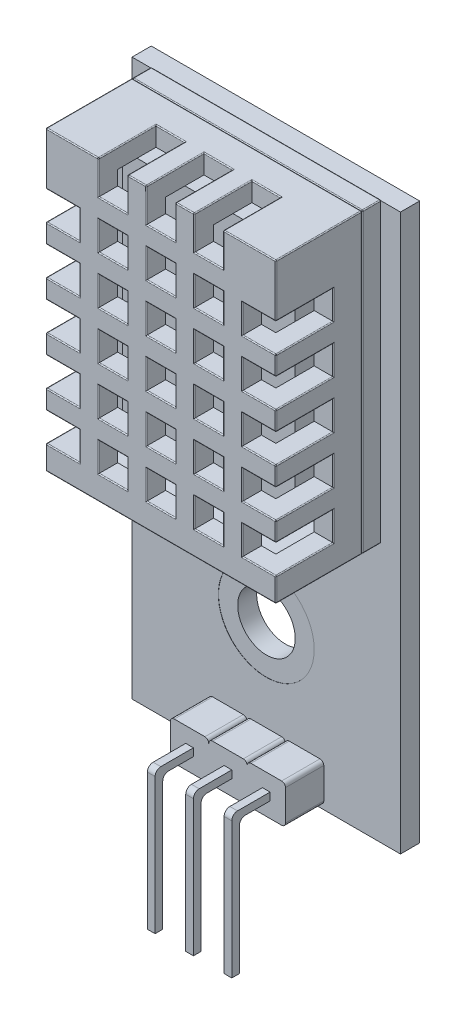
from build123d import *

# Parameters (mm, degrees)
SKETCH1_W           = 12
SKETCH1_H           = 15.5
BOSS_EXTRUDE1_DEPTH = 5.5
SHELL2_T            = -1
SKETCH3_W           = 1.5
SKETCH3_H           = 1.75
CUT_EXTRUDE1_DEPTH  = 3
SKETCH4_W           = 1.5
SKETCH4_H           = 1.5
CUT_EXTRUDE2_DEPTH  = 3
SKETCH5_W           = 1.75
SKETCH5_H           = 1.5
CUT_EXTRUDE3_DEPTH  = 3
SKETCH6_W           = 12
SKETCH6_H           = 15.5
SKETCH6_W_2         = 10
SKETCH6_H_2         = 13.5
CUT_EXTRUDE4_DEPTH  = 1
SKETCH8_W           = 12
SKETCH8_H           = 15.5
BOSS_EXTRUDE3_DEPTH = 0.99
FILLET1_R           = 0.05
FILLET2_R           = 0.05
SKETCH10_W          = 9
SKETCH10_H          = 12.5
BOSS_EXTRUDE4_DEPTH = 2
SKETCH11_W          = 14
SKETCH11_H          = 29
BOSS_EXTRUDE5_DEPTH = 1
BOSS_EXTRUDE6_DEPTH = 2
SKETCH13_W          = 0.4
SKETCH13_H          = 0.39878694
BOSS_EXTRUDE7_DEPTH = 2
SKETCH14_W          = 0.4
SKETCH14_H          = 0.400273
BOSS_EXTRUDE8_DEPTH = 7
FILLET3_R           = 0.3
FILLET4_R           = 0.3
FILLET5_R           = 0.3
FILLET6_R           = 0.3
FILLET7_R           = 0.3
FILLET8_R           = 0.3
SKETCH15_R          = 1.5
CUT_EXTRUDE5_DEPTH  = 2
SKETCH16_R          = 2.5
CUT_EXTRUDE6_DEPTH  = 0.01


with BuildPart() as part:
    # Sketch1 → Boss-Extrude1 (new body)
    with BuildSketch(Plane.XY):
        with Locations((6, 7.75)):
            Rectangle(SKETCH1_W, SKETCH1_H)
    extrude(amount=BOSS_EXTRUDE1_DEPTH)

    # Shell2
    shell2_openings = [part.faces().sort_by_distance(p)[0] for p in [
        (6, 7.75, 0),
    ]]
    offset(amount=SHELL2_T, openings=shell2_openings, kind=Kind.INTERSECTION)

    # Sketch3 → Cut-Extrude1 (cut)
    with BuildSketch(Plane.XY.offset(5.5)):
        with Locations((3.5, 14.625)):
            Rectangle(SKETCH3_W, SKETCH3_H)
        with Locations((6, 14.625)):
            Rectangle(SKETCH3_W, SKETCH3_H)
        with Locations((8.5, 14.625)):
            Rectangle(SKETCH3_W, SKETCH3_H)
    extrude(amount=-CUT_EXTRUDE1_DEPTH, mode=Mode.SUBTRACT)

    # Sketch4 → Cut-Extrude2 (cut)
    with BuildSketch(Plane.XY.offset(5.5)):
        with Locations((3.5, 12)):
            Rectangle(SKETCH4_W, SKETCH4_H)
        with Locations((6, 12)):
            Rectangle(SKETCH4_W, SKETCH4_H)
        with Locations((8.5, 12)):
            Rectangle(SKETCH4_W, SKETCH4_H)
        with Locations((6, 9.5)):
            Rectangle(SKETCH4_W, SKETCH4_H)
        with Locations((8.5, 9.5)):
            Rectangle(SKETCH4_W, SKETCH4_H)
        with Locations((6, 7)):
            Rectangle(SKETCH4_W, SKETCH4_H)
        with Locations((8.5, 7)):
            Rectangle(SKETCH4_W, SKETCH4_H)
        with Locations((6, 4.5)):
            Rectangle(SKETCH4_W, SKETCH4_H)
        with Locations((8.5, 4.5)):
            Rectangle(SKETCH4_W, SKETCH4_H)
        with Locations((6, 2)):
            Rectangle(SKETCH4_W, SKETCH4_H)
        with Locations((8.5, 2)):
            Rectangle(SKETCH4_W, SKETCH4_H)
        with Locations((3.5, 9.5)):
            Rectangle(SKETCH4_W, SKETCH4_H)
        with Locations((3.5, 7)):
            Rectangle(SKETCH4_W, SKETCH4_H)
        with Locations((3.5, 4.5)):
            Rectangle(SKETCH4_W, SKETCH4_H)
        with Locations((3.5, 2)):
            Rectangle(SKETCH4_W, SKETCH4_H)
    extrude(amount=-CUT_EXTRUDE2_DEPTH, mode=Mode.SUBTRACT)

    # Sketch5 → Cut-Extrude3 (cut)
    with BuildSketch(Plane.XY.offset(5.5)):
        with Locations((0.875, 12)):
            Rectangle(SKETCH5_W, SKETCH5_H)
        with Locations((11.125, 12)):
            Rectangle(SKETCH5_W, SKETCH5_H)
        with Locations((11.125, 9.5)):
            Rectangle(SKETCH5_W, SKETCH5_H)
        with Locations((11.125, 7)):
            Rectangle(SKETCH5_W, SKETCH5_H)
        with Locations((11.125, 4.5)):
            Rectangle(SKETCH5_W, SKETCH5_H)
        with Locations((11.125, 2)):
            Rectangle(SKETCH5_W, SKETCH5_H)
        with Locations((0.875, 9.5)):
            Rectangle(SKETCH5_W, SKETCH5_H)
        with Locations((0.875, 7)):
            Rectangle(SKETCH5_W, SKETCH5_H)
        with Locations((0.875, 4.5)):
            Rectangle(SKETCH5_W, SKETCH5_H)
        with Locations((0.875, 2)):
            Rectangle(SKETCH5_W, SKETCH5_H)
    extrude(amount=-CUT_EXTRUDE3_DEPTH, mode=Mode.SUBTRACT)

    # Sketch6 → Cut-Extrude4 (cut)
    with BuildSketch(Plane(origin=(0, 0, 0), x_dir=(-1, 0, 0), z_dir=(0, 0, -1))):
        with Locations((-6, 7.75)):
            Rectangle(SKETCH6_W, SKETCH6_H)
        with Locations((-6, 7.75)):
            Rectangle(SKETCH6_W_2, SKETCH6_H_2, mode=Mode.SUBTRACT)
    extrude(amount=-CUT_EXTRUDE4_DEPTH, mode=Mode.SUBTRACT)

    # Fillet1
    fillet1_edges = [part.edges().sort_by_distance(p)[0] for p in [
        (12, 0.625, 5.5),
        (5.25, 12, 5.5),
        (6, 11.25, 5.5),
        (6.75, 12, 5.5),
        (6, 12.75, 5.5),
        (10.625, 15.5, 5.5),
        (7.75, 12, 5.5),
        (8.5, 11.25, 5.5),
        (9.25, 12, 5.5),
        (8.5, 12.75, 5.5),
        (5.25, 9.5, 5.5),
        (6, 8.75, 5.5),
        (6.75, 9.5, 5.5),
        (6, 10.25, 5.5),
        (7.75, 9.5, 5.5),
        (8.5, 8.75, 5.5),
        (9.25, 9.5, 5.5),
        (8.5, 10.25, 5.5),
        (5.25, 7, 5.5),
        (6, 6.25, 5.5),
        (6.75, 7, 5.5),
        (6, 7.75, 5.5),
        (7.75, 7, 5.5),
        (8.5, 6.25, 5.5),
        (9.25, 7, 5.5),
        (8.5, 7.75, 5.5),
        (5.25, 4.5, 5.5),
        (6, 3.75, 5.5),
        (6.75, 4.5, 5.5),
        (6, 5.25, 5.5),
        (7.75, 4.5, 5.5),
        (8.5, 3.75, 5.5),
        (9.25, 4.5, 5.5),
        (8.5, 5.25, 5.5),
        (5.25, 2, 5.5),
        (6, 1.25, 5.5),
        (6.75, 2, 5.5),
        (6, 2.75, 5.5),
        (7.75, 2, 5.5),
        (8.5, 1.25, 5.5),
        (9.25, 2, 5.5),
        (8.5, 2.75, 5.5),
        (2.75, 9.5, 5.5),
        (3.5, 8.75, 5.5),
        (4.25, 9.5, 5.5),
        (3.5, 10.25, 5.5),
        (1.375, 15.5, 5.5),
        (2.75, 7, 5.5),
        (3.5, 6.25, 5.5),
        (4.25, 7, 5.5),
        (3.5, 7.75, 5.5),
        (2.75, 4.5, 5.5),
        (3.5, 3.75, 5.5),
        (4.25, 4.5, 5.5),
        (3.5, 5.25, 5.5),
        (2.75, 2, 5.5),
        (3.5, 1.25, 5.5),
        (4.25, 2, 5.5),
        (3.5, 2.75, 5.5),
        (3.5, 15.5, 2.5),
        (2.75, 15.5, 4),
        (4.25, 15.5, 4),
        (2.75, 14.625, 5.5),
        (3.5, 13.75, 5.5),
        (4.25, 14.625, 5.5),
        (0, 10.75, 5.5),
        (0, 12, 2.5),
        (0, 11.25, 4),
        (0, 12.75, 4),
        (0.875, 11.25, 5.5),
        (1.75, 12, 5.5),
        (0.875, 12.75, 5.5),
        (12, 14.125, 5.5),
        (12, 12, 2.5),
        (12, 12.75, 4),
        (12, 11.25, 4),
        (10.25, 12, 5.5),
        (11.125, 11.25, 5.5),
        (11.125, 12.75, 5.5),
        (12, 10.75, 5.5),
        (0, 14.125, 5.5),
        (12, 9.5, 2.5),
        (12, 10.25, 4),
        (12, 8.75, 4),
        (10.25, 9.5, 5.5),
        (11.125, 8.75, 5.5),
        (11.125, 10.25, 5.5),
        (12, 8.25, 5.5),
        (12, 7, 2.5),
        (12, 7.75, 4),
        (12, 6.25, 4),
        (10.25, 7, 5.5),
        (11.125, 6.25, 5.5),
        (11.125, 7.75, 5.5),
        (12, 5.75, 5.5),
        (12, 4.5, 2.5),
        (12, 5.25, 4),
        (12, 3.75, 4),
        (10.25, 4.5, 5.5),
        (11.125, 3.75, 5.5),
        (11.125, 5.25, 5.5),
        (12, 3.25, 5.5),
        (12, 2, 2.5),
        (12, 2.75, 4),
        (12, 1.25, 4),
        (10.25, 2, 5.5),
        (11.125, 1.25, 5.5),
        (11.125, 2.75, 5.5),
        (0, 8.25, 5.5),
        (0, 9.5, 2.5),
        (0, 8.75, 4),
        (0, 10.25, 4),
        (0.875, 8.75, 5.5),
        (1.75, 9.5, 5.5),
        (0.875, 10.25, 5.5),
        (4.75, 15.5, 5.5),
        (0, 5.75, 5.5),
        (0, 7, 2.5),
        (0, 6.25, 4),
        (0, 7.75, 4),
        (0.875, 6.25, 5.5),
        (1.75, 7, 5.5),
        (0.875, 7.75, 5.5),
        (0, 3.25, 5.5),
        (0, 4.5, 2.5),
        (0, 3.75, 4),
        (0, 5.25, 4),
        (0.875, 3.75, 5.5),
        (1.75, 4.5, 5.5),
        (0.875, 5.25, 5.5),
        (0, 0.625, 5.5),
        (6, 15.5, 2.5),
        (0, 2, 2.5),
        (0, 1.25, 4),
        (0, 2.75, 4),
        (0.875, 1.25, 5.5),
        (1.75, 2, 5.5),
        (0.875, 2.75, 5.5),
        (5.25, 15.5, 4),
        (6.75, 15.5, 4),
        (5.25, 14.625, 5.5),
        (6, 13.75, 5.5),
        (6.75, 14.625, 5.5),
        (6, 0, 1),
        (12, 7.75, 1),
        (6, 15.5, 1),
        (0, 7.75, 1),
        (7.25, 15.5, 5.5),
        (6, 0, 5.5),
        (8.5, 15.5, 2.5),
        (0, 15.5, 3.25),
        (7.75, 15.5, 4),
        (9.25, 15.5, 4),
        (7.75, 14.625, 5.5),
        (12, 15.5, 3.25),
        (8.5, 13.75, 5.5),
        (9.25, 14.625, 5.5),
        (12, 0, 3.25),
        (0, 0, 3.25),
        (2.75, 12, 5.5),
        (3.5, 11.25, 5.5),
        (4.25, 12, 5.5),
        (3.5, 12.75, 5.5),
    ]]
    fillet(fillet1_edges, radius=FILLET1_R)


with BuildPart() as body_2:
    # Sketch8 → Boss-Extrude3 (new body)
    with BuildSketch(Plane.XY.offset(0.99)):
        with Locations((6, 7.75)):
            Rectangle(SKETCH8_W, SKETCH8_H)
    extrude(amount=-BOSS_EXTRUDE3_DEPTH)

    # Fillet2
    fillet2_edges = [body_2.edges().sort_by_distance(p)[0] for p in [
        (0, 7.75, 0),
        (6, 0, 0),
        (12, 7.75, 0),
        (6, 0, 0.99),
        (0, 7.75, 0.99),
        (6, 15.5, 0.99),
        (12, 7.75, 0.99),
        (6, 15.5, 0),
        (12, 0, 0.495),
        (0, 0, 0.495),
        (0, 15.5, 0.495),
        (12, 15.5, 0.495),
    ]]
    fillet(fillet2_edges, radius=FILLET2_R)

    # Sketch10 → Boss-Extrude4 (add)
    with BuildSketch(Plane.XY.offset(0.99)):
        with Locations((6, 7.75)):
            Rectangle(SKETCH10_W, SKETCH10_H)
    extrude(amount=BOSS_EXTRUDE4_DEPTH)

    # Sketch11 → Boss-Extrude5 (add)
    with BuildSketch(Plane(origin=(0, 0, 0), x_dir=(-1, 0, 0), z_dir=(0, 0, -1))):
        with Locations((-6, 0.95)):
            Rectangle(SKETCH11_W, SKETCH11_H)
    extrude(amount=BOSS_EXTRUDE5_DEPTH)

    # Sketch12 → Boss-Extrude6 (add)
    with BuildSketch(Plane.XY):
        with BuildLine():
            Line((4.8, -13.35), (3.2, -13.35))
            ThreePointArc((3.2, -13.35), (3.058578644, -13.291421356), (3, -13.15))
            Line((3, -13.15), (3, -11.55))
            ThreePointArc((3, -11.55), (3.058578644, -11.408578644), (3.2, -11.35))
            Line((3.2, -11.35), (4.8, -11.35))
            ThreePointArc((4.8, -11.35), (4.941421356, -11.408578644), (5, -11.55))
            Line((5, -11.55), (5, -13.15))
            ThreePointArc((5, -13.15), (4.941421356, -13.291421356), (4.8, -13.35))
        make_face()
        with BuildLine():
            Line((7, -11.55), (7, -13.15))
            ThreePointArc((7, -13.15), (6.941421356, -13.291421356), (6.8, -13.35))
            Line((6.8, -13.35), (5.2, -13.35))
            ThreePointArc((5.2, -13.35), (5.058578644, -13.291421356), (5, -13.15))
            Line((5, -13.15), (5, -11.55))
            ThreePointArc((5, -11.55), (5.058578644, -11.408578644), (5.2, -11.35))
            Line((5.2, -11.35), (6.8, -11.35))
            ThreePointArc((6.8, -11.35), (6.941421356, -11.408578644), (7, -11.55))
        make_face()
        with BuildLine():
            ThreePointArc((9, -13.15), (8.941421356, -13.291421356), (8.8, -13.35))
            Line((8.8, -13.35), (7.2, -13.35))
            ThreePointArc((7.2, -13.35), (7.058578644, -13.291421356), (7, -13.15))
            Line((7, -13.15), (7, -11.55))
            ThreePointArc((7, -11.55), (7.058578644, -11.408578644), (7.2, -11.35))
            Line((7.2, -11.35), (8.8, -11.35))
            ThreePointArc((8.8, -11.35), (8.941421356, -11.408578644), (9, -11.55))
            Line((9, -11.55), (9, -13.15))
        make_face()
    extrude(amount=BOSS_EXTRUDE6_DEPTH)

    # Sketch13 → Boss-Extrude7 (add)
    with BuildSketch(Plane.XY.offset(2)):
        with Locations((4, -12.35)):
            Rectangle(SKETCH13_W, SKETCH13_H)
        with Locations((6, -12.35)):
            Rectangle(SKETCH13_W, SKETCH13_H)
        with Locations((8, -12.35)):
            Rectangle(SKETCH13_W, SKETCH13_H)
    extrude(amount=BOSS_EXTRUDE7_DEPTH)

    # Sketch14 → Boss-Extrude8 (add)
    with BuildSketch(Plane.XZ.offset(12.54939347)):
        with Locations((6, 3.7998635)):
            Rectangle(SKETCH14_W, SKETCH14_H)
        with Locations((4, 3.7998635)):
            Rectangle(SKETCH14_W, SKETCH14_H)
        with Locations((8, 3.7998635)):
            Rectangle(SKETCH14_W, SKETCH14_H)
    extrude(amount=BOSS_EXTRUDE8_DEPTH)

    # Fillet3
    fillet3_edges = [body_2.edges().sort_by_distance(p)[0] for p in [
        (4, -12.54939347, 3.599727),
    ]]
    fillet(fillet3_edges, radius=FILLET3_R)

    # Fillet4
    fillet4_edges = [body_2.edges().sort_by_distance(p)[0] for p in [
        (6, -12.54939347, 3.599727),
    ]]
    fillet(fillet4_edges, radius=FILLET4_R)

    # Fillet5
    fillet5_edges = [body_2.edges().sort_by_distance(p)[0] for p in [
        (8, -12.54939347, 3.599727),
    ]]
    fillet(fillet5_edges, radius=FILLET5_R)

    # Fillet6
    fillet6_edges = [body_2.edges().sort_by_distance(p)[0] for p in [
        (4, -12.15060653, 4),
    ]]
    fillet(fillet6_edges, radius=FILLET6_R)

    # Fillet7
    fillet7_edges = [body_2.edges().sort_by_distance(p)[0] for p in [
        (6, -12.15060653, 4),
    ]]
    fillet(fillet7_edges, radius=FILLET7_R)

    # Fillet8
    fillet8_edges = [body_2.edges().sort_by_distance(p)[0] for p in [
        (8, -12.15060653, 4),
    ]]
    fillet(fillet8_edges, radius=FILLET8_R)

    # Sketch15 → Cut-Extrude5 (cut, through all)
    with BuildSketch(Plane.XY):
        with Locations((6, -6.566844141)):
            Circle(SKETCH15_R)
    extrude(amount=-CUT_EXTRUDE5_DEPTH, mode=Mode.SUBTRACT)

    # Sketch16 → Cut-Extrude6 (cut)
    with BuildSketch(Plane.XY):
        with Locations((6, -6.566844141)):
            Circle(SKETCH16_R)
    extrude(amount=-CUT_EXTRUDE6_DEPTH, mode=Mode.SUBTRACT)


solid = Compound([part.part, body_2.part])
